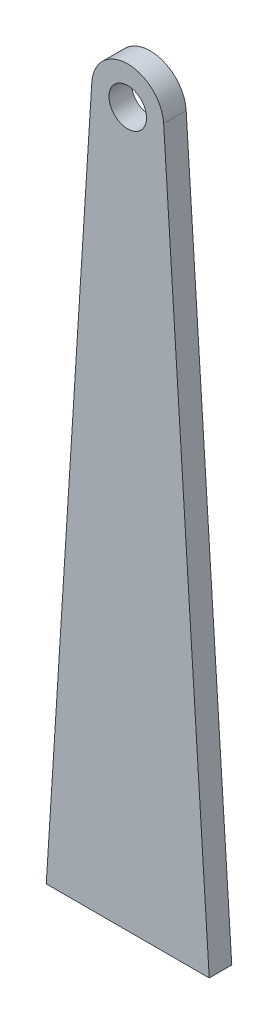
from build123d import *

# Parameters (mm, degrees)
SKETCH1_R           = 2.5
BOSS_EXTRUDE1_DEPTH = 3


with BuildPart() as part:
    # Sketch1 → Boss-Extrude1 (new body)
    with BuildSketch(Plane.XY):
        with BuildLine():
            Line((10.853563951, -84.90575827), (-10.853563951, -84.90575827))
            Line((-10.853563951, -84.90575827), (-4.782100014, 10.606475312))
            ThreePointArc((-4.782100014, 10.606475312), (-3.279044371, 13.796592676), (0, 15.09424173))
            ThreePointArc((0, 15.09424173), (3.279044371, 13.796592676), (4.782100014, 10.606475312))
            Line((4.782100014, 10.606475312), (10.853563951, -84.90575827))
        make_face()
        with Locations((0, 10.09424173)):
            Circle(SKETCH1_R, mode=Mode.SUBTRACT)
    extrude(amount=BOSS_EXTRUDE1_DEPTH)


solid = part.part
